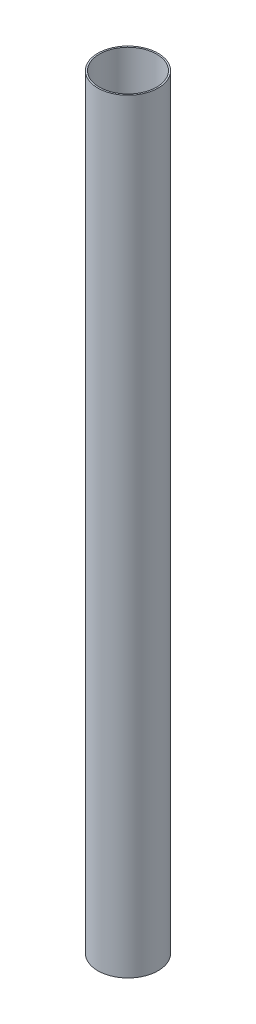
from build123d import *

# Parameters (mm, degrees)
SKETCH1_R           = 10
SKETCH1_R_2         = 9.5
BOSS_EXTRUDE1_DEPTH = 253.5


with BuildPart() as part:
    # Sketch1 → Boss-Extrude1 (new body)
    with BuildSketch(Plane(origin=(0, 0, 0), x_dir=(1, 0, 0), z_dir=(0, 1, 0))):
        with Locations(Location((0, 0, 0), (0, 0, 270))):  # turned: the seam where the file's is
            Circle(SKETCH1_R)
        with Locations(Location((0, 0, 0), (0, 0, 270))):  # turned: the seam where the file's is
            Circle(SKETCH1_R_2, mode=Mode.SUBTRACT)
    extrude(amount=BOSS_EXTRUDE1_DEPTH)


solid = part.part
